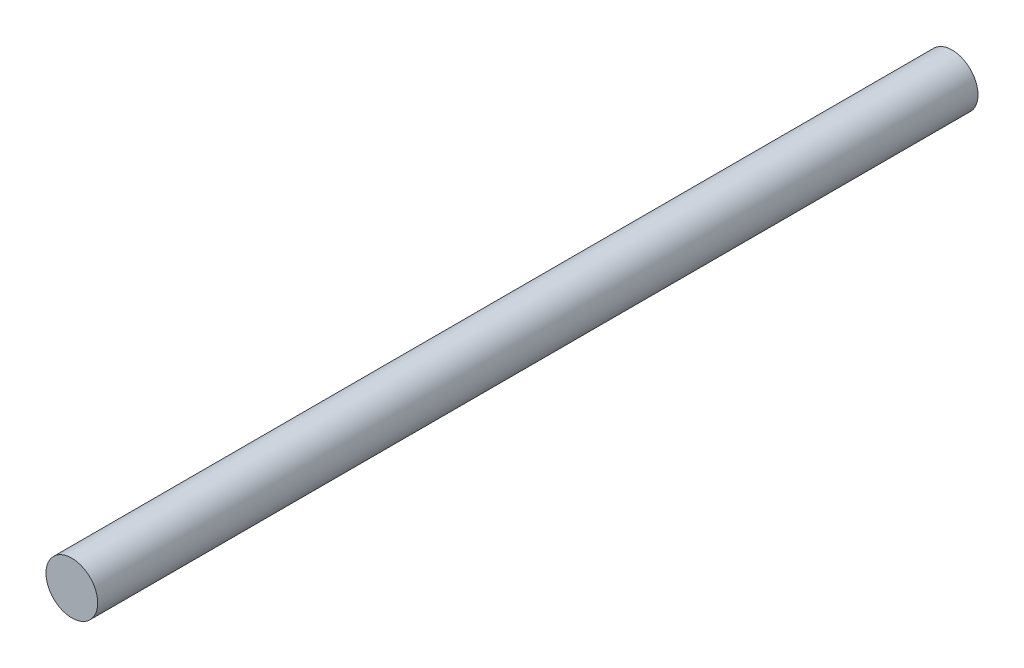
from build123d import *

# Parameters (mm, degrees)
IZIM1_R                     = 2
Y_KSEKLIK_EKSTR_ZYON1_DEPTH = 68


with BuildPart() as part:
    # Çizim1 → Yükseklik-Ekstrüzyon1 (new body)
    with BuildSketch(Plane.XY):
        Circle(IZIM1_R)
    extrude(amount=Y_KSEKLIK_EKSTR_ZYON1_DEPTH)


solid = part.part
